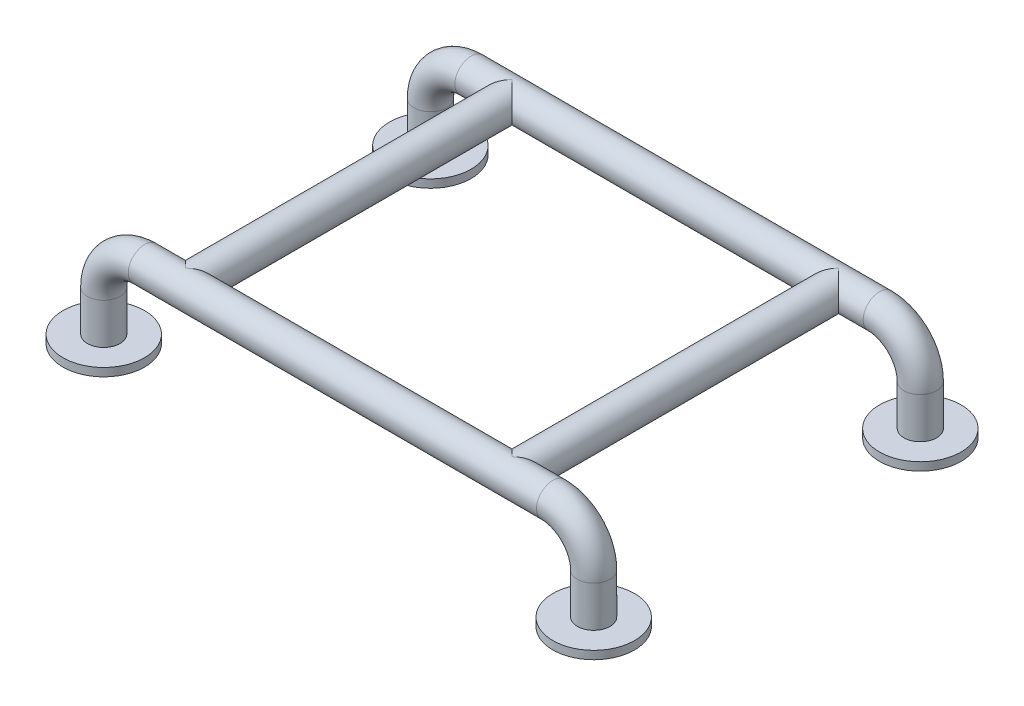
from build123d import *

# Parameters (mm, degrees)
SKETCH3_R           = 20
SKETCH4_R           = 50
BOSS_EXTRUDE1_DEPTH = 10
SKETCH7_R           = 20
SKETCH9_R           = 50
BOSS_EXTRUDE2_DEPTH = 10
SKETCH11_R          = 20
BOSS_EXTRUDE3_DEPTH = 400


with BuildPart() as part:
    # Sweep1: sweep along a path in Sketch2
    with BuildLine(Plane.XY) as sweep1_path:
        Line((0, 0), (0, 50))
        ThreePointArc((0, 50), (14.644660941, 85.355339059), (50, 100))
        Line((50, 100), (550, 100))
        ThreePointArc((550, 100), (585.355339059, 85.355339059), (600, 50))
        Line((600, 50), (600, 0))
    # Sketch3 → Sweep1 (sweep)
    with BuildSketch(Plane(origin=(0, 0, 0), x_dir=(1, 0, 0), z_dir=(0, 1, 0))):
        Circle(SKETCH3_R)
    sweep(path=sweep1_path.line)

    # Sketch4 → Boss-Extrude1 (add)
    with BuildSketch(Plane.XZ):
        Circle(SKETCH4_R)
        with Locations((600, 0)):
            Circle(SKETCH4_R)
    extrude(amount=BOSS_EXTRUDE1_DEPTH)

    # Sketch11 → Boss-Extrude3 (add)
    with BuildSketch(Plane.XY):
        with Locations((100, 100)):
            Circle(SKETCH11_R)
        with Locations((500, 100)):
            Circle(SKETCH11_R)
    extrude(amount=BOSS_EXTRUDE3_DEPTH)


with BuildPart() as body_2:
    # Sweep2: sweep along a path in Sketch5
    with BuildLine(Plane.XY.offset(400)) as sweep2_path:
        Line((0, 0), (0, 50))
        ThreePointArc((0, 50), (14.644660941, 85.355339059), (50, 100))
        Line((50, 100), (550, 100))
        ThreePointArc((550, 100), (585.355339059, 85.355339059), (600, 50))
        Line((600, 50), (600, -10))
    # Sketch7 → Sweep2 (sweep)
    with BuildSketch(Plane(origin=(0, 0, 0), x_dir=(1, 0, 0), z_dir=(0, 1, 0))):
        with Locations((0, -400)):
            Circle(SKETCH7_R)
    sweep(path=sweep2_path.line)

    # Sketch9 → Boss-Extrude2 (add)
    with BuildSketch(Plane.XZ):
        with Locations((0, 400)):
            Circle(SKETCH9_R)
        with Locations((600, 400)):
            Circle(SKETCH9_R)
    extrude(amount=BOSS_EXTRUDE2_DEPTH)


solid = Compound([part.part, body_2.part])
